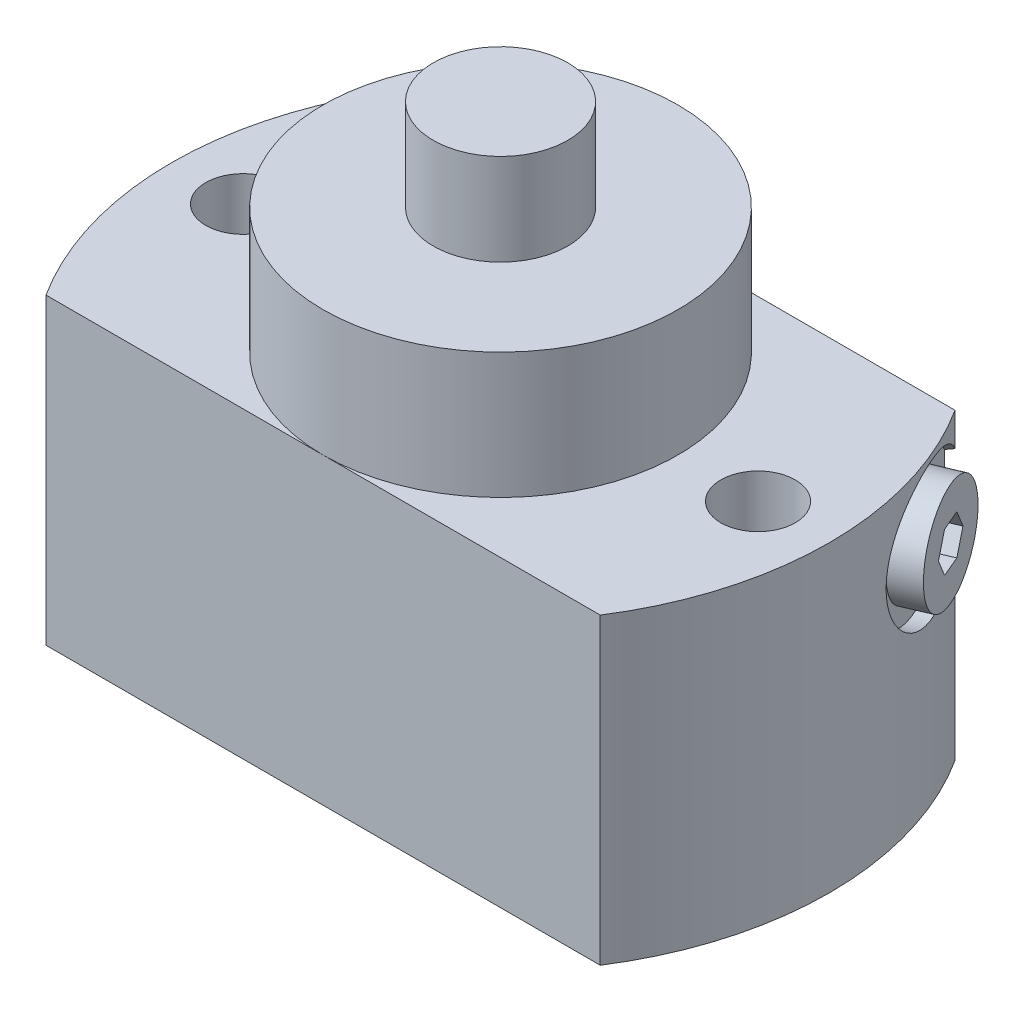
from build123d import *

# Parameters (mm, degrees)
EXTRUDE1_DEPTH     = 53
HOLE1_D            = 13
HOLE1_DEPTH        = 53
SKETCH5_R          = 4
CUT_EXTRUDE1_DEPTH = 4
SKETCH6_R          = 5.5
CUT_EXTRUDE2_DEPTH = 3
SKETCH7_R          = 2
CUT_EXTRUDE3_DEPTH = 33
CUT_EXTRUDE4_DEPTH = 5


with BuildPart() as part:
    # Sketch1 → Extrude1 (new body)
    with BuildSketch(Plane(origin=(0, 0, 0), x_dir=(1, 0, 0), z_dir=(0, 1, 0))):
        with BuildLine():
            Line((-48.427781283, 31), (48.427781283, 31))
            ThreePointArc((48.427781283, 31), (57.5, 0), (48.427781283, -31))
            Line((48.427781283, -31), (-48.427781283, -31))
            ThreePointArc((-48.427781283, -31), (-57.5, 0), (-48.427781283, 31))
        make_face()
    extrude(amount=EXTRUDE1_DEPTH)

    # Sketch2 → Revolve1 (revolve)
    with BuildSketch(Plane.XY, mode=Mode.PRIVATE) as revolve1_sk:
        Polygon((0, 91), (-11.75, 91), (-11.75, 75), (-31, 75), (-31, 53), (0, 53), align=None)
    revolve(revolve1_sk.sketch.rotate(Axis((0, 0, 0), (0, 1, 0)), 270), axis=Axis((0, 0, 0), (0, 1, 0)))  # turned: the seam where the file's is

    # Hole1
    with Locations(Plane(origin=(0, 53, 0), x_dir=(-1, 0, 0), z_dir=(0, 1, 0))):
        with Locations((45, 0), (-45, 0)):
            Hole(HOLE1_D / 2, depth=HOLE1_DEPTH)

    # Sketch5 → Cut-Extrude1 (cut)
    with BuildSketch(Plane.XZ):
        with Locations(Location((0, 0, 0), (0, 0, 270))):  # turned: the seam where the file's is
            Circle(SKETCH5_R)
    extrude(amount=-CUT_EXTRUDE1_DEPTH, mode=Mode.SUBTRACT)

    # Sketch6 → Cut-Extrude2 (cut)
    with BuildSketch(Plane.XZ):
        with Locations(Location((35, -15, 0), (0, 0, 270))):  # turned: the seam where the file's is
            Circle(SKETCH6_R)
    extrude(amount=-CUT_EXTRUDE2_DEPTH, mode=Mode.SUBTRACT)

    # Sketch7 → Cut-Extrude3 (cut)
    with BuildSketch(Plane.XZ.offset(-3)):
        with Locations(Location((35, -15, 0), (0, 0, 270))):  # turned: the seam where the file's is
            Circle(SKETCH7_R)
    extrude(amount=-CUT_EXTRUDE3_DEPTH, mode=Mode.SUBTRACT)

    # Sketch8 → Cut-Revolve1 (revolve, cut)
    with BuildSketch(Plane(origin=(0, 0, 0), x_dir=(0.920504853, 0, -0.390731128), z_dir=(0.390731128, 0, 0.920504853)), mode=Mode.PRIVATE) as cut_revolve1_sk:
        Polygon((57.5, 28), (55, 28), (55, 33.4215), (53.517364509, 34.2775), (35, 34.2775), (35, 40), (57.5, 40), align=None)
    revolve(cut_revolve1_sk.sketch.rotate(Axis((47.484793311, 40, -20.156098913), (-0.920504853, 0, 0.390731128)), 270), axis=Axis((47.484793311, 40, -20.156098913), (-0.920504853, 0, 0.390731128)), mode=Mode.SUBTRACT)  # turned: the seam where the file's is

    # Sketch9 → Revolve2 (revolve)
    with BuildSketch(Plane(origin=(0, 0, 0), x_dir=(0.920504853, 0, -0.390731128), z_dir=(0.390731128, 0, 0.920504853)), mode=Mode.PRIVATE) as revolve2_sk:
        Polygon((55, 31), (55, 34.2775), (46, 34.2775), (45, 35.2775), (45, 40), (60, 40), (60, 31), align=None)
    revolve(revolve2_sk.sketch.rotate(Axis((68.658528533, 40, -29.14381628), (-0.920504853, 0, 0.390731128)), 270), axis=Axis((68.658528533, 40, -29.14381628), (-0.920504853, 0, 0.390731128)))  # turned: the seam where the file's is

    # Sketch10 → Cut-Extrude4 (cut)
    with BuildSketch(Plane(origin=(55.230291207, 0, -23.443867709), x_dir=(-0.390731128, 0, -0.920504853), z_dir=(0.920504853, 0, -0.390731128))):
        Polygon((4.041451884, 40), (2.020725942, 43.5), (-2.020725942, 43.5), (-4.041451884, 40), (-2.020725942, 36.5), (2.020725942, 36.5), align=None)
    extrude(amount=-CUT_EXTRUDE4_DEPTH, mode=Mode.SUBTRACT)


solid = part.part
